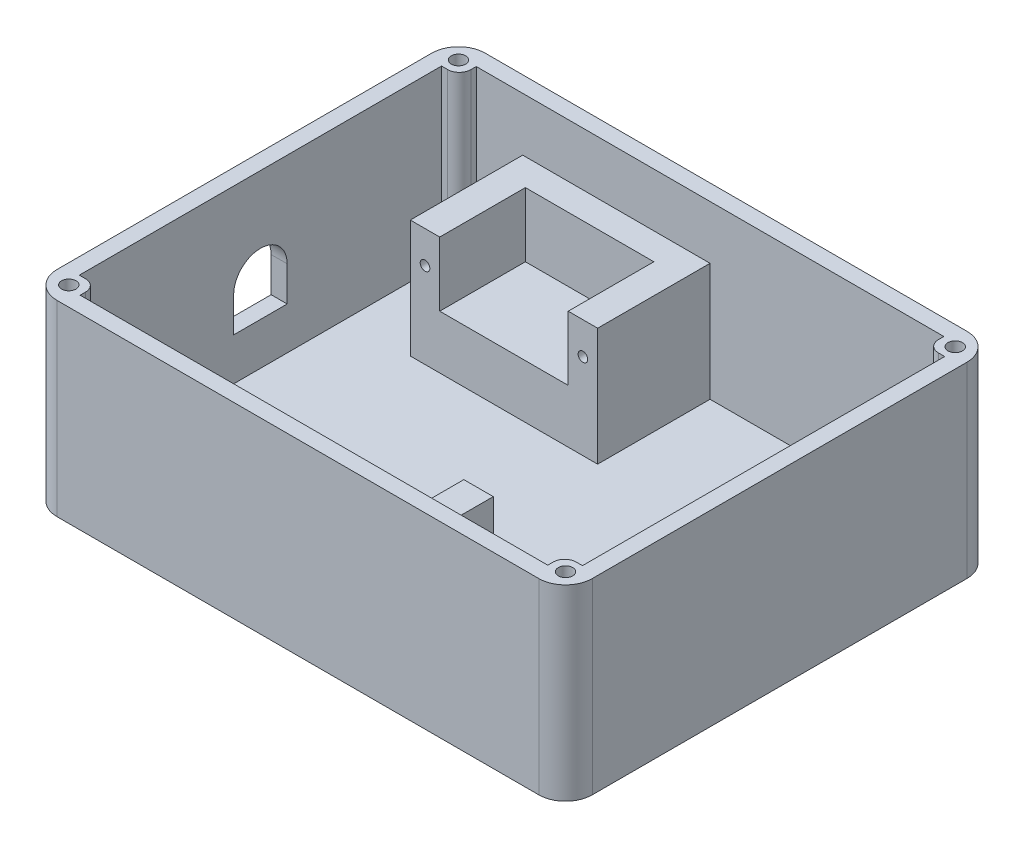
from build123d import *

# Parameters (mm, degrees)
EXTRUDE_1_DEPTH     = 35
SHELL_2_T           = -3
EXTRUDE_3_DEPTH     = 32
SKETCH_3_R          = 1.35
CUT_EXTRUDE_1_DEPTH = 4
CUT_EXTRUDE_4_DEPTH = 3
SKETCH_7_W          = 35
SKETCH_7_H          = 21
SKETCH_7_H_2        = 16
EXTRUDE_4_DEPTH     = 22
SKETCH_8_W          = 24
SKETCH_8_H          = 16
CUT_EXTRUDE_5_DEPTH = 12
SKETCH_9_R          = 0.9
CUT_EXTRUDE_6_DEPTH = 5
SKETCH_10_R         = 0.9
CUT_EXTRUDE_7_DEPTH = 4


with BuildPart() as part:
    # 草图1 → 凸台-拉伸1 (new body)
    with BuildSketch(Plane(origin=(0, 0, 0), x_dir=(1, 0, 0), z_dir=(0, 1, 0))):
        with BuildLine():
            Line((-45, 40), (45, 40))
            ThreePointArc((45, 40), (48.535533906, 38.535533906), (50, 35))
            Line((50, 35), (50, -35))
            ThreePointArc((50, -35), (48.535533906, -38.535533906), (45, -40))
            Line((45, -40), (-45, -40))
            ThreePointArc((-45, -40), (-48.535533906, -38.535533906), (-50, -35))
            Line((-50, -35), (-50, 35))
            ThreePointArc((-50, 35), (-48.535533906, 38.535533906), (-45, 40))
        make_face()
    extrude(amount=EXTRUDE_1_DEPTH)

    # 抽壳2
    shell_2_openings = [part.faces().sort_by_distance(p)[0] for p in [
        (0, 35, 0),
    ]]
    offset(amount=SHELL_2_T, openings=shell_2_openings, kind=Kind.INTERSECTION)

    # 草图2 → 凸台-拉伸3 (add)
    with BuildSketch(Plane(origin=(0, 3, 0), x_dir=(1, 0, 0), z_dir=(0, 1, 0))):
        with BuildLine():
            Line((47, 33.834963516), (47, 35))
            ThreePointArc((47, 35), (46.414213562, 36.414213562), (45, 37))
            Line((45, 37), (43.678814145, 37))
            Line((43.678814145, 37), (43.678814145, 36))
            ThreePointArc((43.678814145, 36), (44.31293865, 34.46908802), (45.843850629, 33.834963516))
            Line((45.843850629, 33.834963516), (47, 33.834963516))
        make_face()
        with BuildLine():
            Line((-43.678814145, 36), (-43.678814145, 37))
            Line((-43.678814145, 37), (-45, 37))
            ThreePointArc((-45, 37), (-46.414213562, 36.414213562), (-47, 35))
            Line((-47, 35), (-47, 33.834963516))
            Line((-47, 33.834963516), (-45.843850629, 33.834963516))
            ThreePointArc((-45.843850629, 33.834963516), (-44.31293865, 34.46908802), (-43.678814145, 36))
        make_face()
        with BuildLine():
            Line((43.678814145, -37), (45, -37))
            ThreePointArc((45, -37), (46.414213562, -36.414213562), (47, -35))
            Line((47, -35), (47, -33.834963516))
            Line((47, -33.834963516), (45.843850629, -33.834963516))
            ThreePointArc((45.843850629, -33.834963516), (44.31293865, -34.46908802), (43.678814145, -36))
            Line((43.678814145, -36), (43.678814145, -37))
        make_face()
        with BuildLine():
            Line((-47, -33.834963516), (-47, -35))
            ThreePointArc((-47, -35), (-46.414213562, -36.414213562), (-45, -37))
            Line((-45, -37), (-43.678814145, -37))
            Line((-43.678814145, -37), (-43.678814145, -36))
            ThreePointArc((-43.678814145, -36), (-44.31293865, -34.46908802), (-45.843850629, -33.834963516))
            Line((-45.843850629, -33.834963516), (-47, -33.834963516))
        make_face()
    extrude(amount=EXTRUDE_3_DEPTH)

    # 草图3 → 切除-拉伸1 (cut)
    with BuildSketch(Plane(origin=(0, 35, 0), x_dir=(1, 0, 0), z_dir=(0, 1, 0))):
        with Locations((-46.4, 36.4)):
            Circle(SKETCH_3_R)
        with Locations((46.4, 36.4)):
            Circle(SKETCH_3_R)
        with Locations((46.4, -36.4)):
            Circle(SKETCH_3_R)
        with Locations((-46.4, -36.4)):
            Circle(SKETCH_3_R)
    extrude(amount=-CUT_EXTRUDE_1_DEPTH, mode=Mode.SUBTRACT)

    # 草图6 → 切除-拉伸4 (cut)
    with BuildSketch(Plane.ZY.offset(50)):
        with BuildLine():
            Line((-5, 17.418982567), (-5, 10.918982567))
            Line((-5, 10.918982567), (5, 10.918982567))
            Line((5, 10.918982567), (5, 17.418982567))
            ThreePointArc((5, 17.418982567), (0, 22.418982567), (-5, 17.418982567))
        make_face()
    extrude(amount=-CUT_EXTRUDE_4_DEPTH, mode=Mode.SUBTRACT)

    # 草图7 → 凸台-拉伸4 (add)
    with BuildSketch(Plane(origin=(0, 3, 0), x_dir=(1, 0, 0), z_dir=(0, 1, 0))):
        with Locations((-17.5, 26.5)):
            Rectangle(SKETCH_7_W, SKETCH_7_H)
        with Locations((29.5, -29)):
            Rectangle(SKETCH_7_W, SKETCH_7_H_2)
    extrude(amount=EXTRUDE_4_DEPTH)

    # 草图8 → 切除-拉伸5 (cut)
    with BuildSketch(Plane(origin=(0, 25, 0), x_dir=(1, 0, 0), z_dir=(0, 1, 0))):
        with Locations((29.5, -29)):
            Rectangle(SKETCH_8_W, SKETCH_8_H)
        with Locations((-17.5, 24)):
            Rectangle(SKETCH_8_W, SKETCH_8_H)
    extrude(amount=-CUT_EXTRUDE_5_DEPTH, mode=Mode.SUBTRACT)

    # 草图9 → 切除-拉伸6 (cut)
    with BuildSketch(Plane.XY.offset(-16)):
        with Locations((-2.75, 19)):
            Circle(SKETCH_9_R)
        with Locations((-32.25, 19)):
            Circle(SKETCH_9_R)
    extrude(amount=-CUT_EXTRUDE_6_DEPTH, mode=Mode.SUBTRACT)

    # 草图10 → 切除-拉伸7 (cut)
    with BuildSketch(Plane(origin=(0, 0, 21), x_dir=(-1, 0, 0), z_dir=(0, 0, -1))):
        with Locations((-44, 19)):
            Circle(SKETCH_10_R)
        with Locations((-15, 19)):
            Circle(SKETCH_10_R)
    extrude(amount=-CUT_EXTRUDE_7_DEPTH, mode=Mode.SUBTRACT)


solid = part.part
